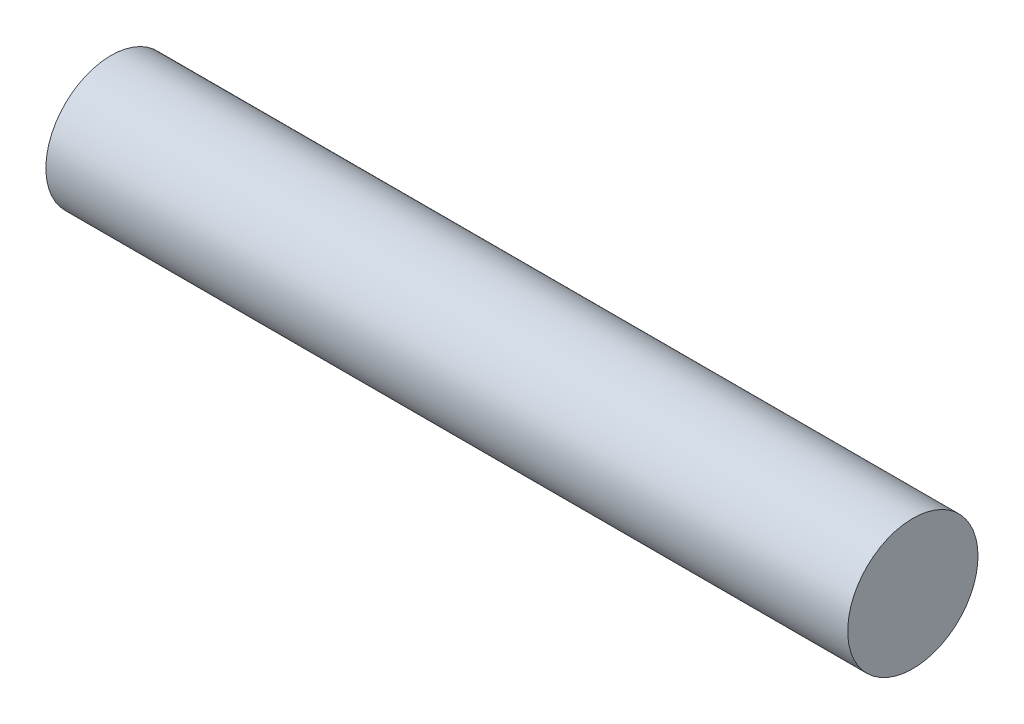
from build123d import *

# Parameters (mm, degrees)
SKETCH1_R      = 0.65
EXTRUDE1_DEPTH = 8


with BuildPart() as part:
    # Sketch1 → Extrude1 (new body)
    with BuildSketch(Plane(origin=(0, 0, 0), x_dir=(0, 0, -1), z_dir=(1, 0, 0))):
        Circle(SKETCH1_R)
    extrude(amount=EXTRUDE1_DEPTH)


solid = part.part
